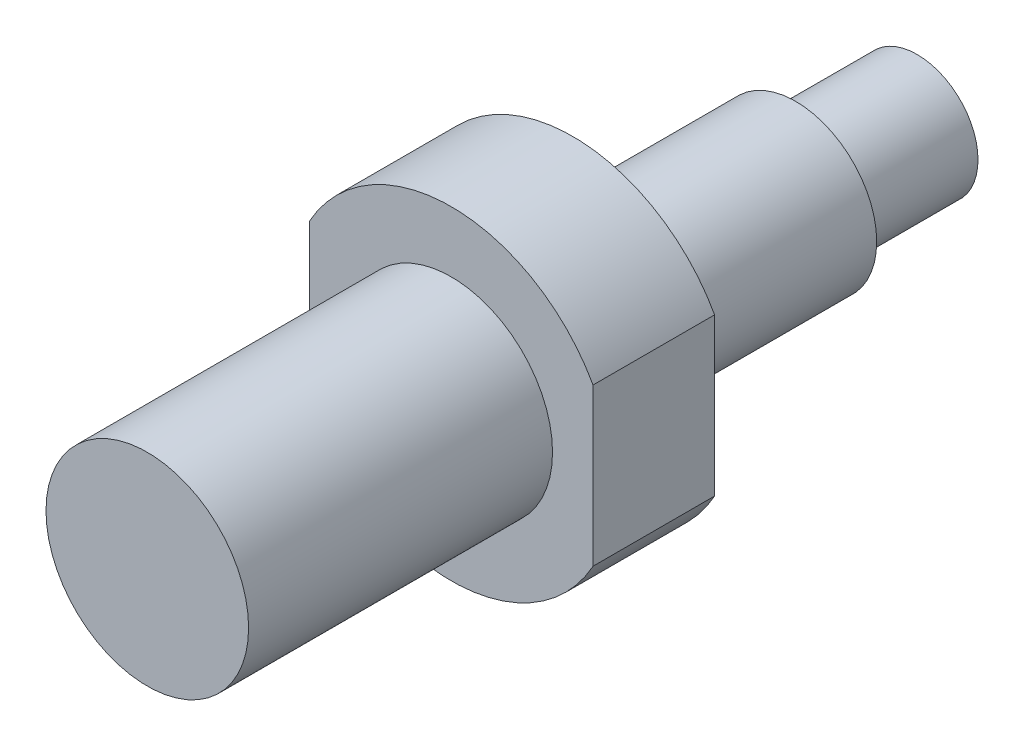
from build123d import *

# Parameters (mm, degrees)
SKETCH_3_W          = 8
SKETCH_3_H          = 16.823898374
CUT_EXTRUDE_1_DEPTH = 10
SKETCH_5_OUTSIDE_W  = 23.858
SKETCH_5_OUTSIDE_H  = 27.858
SKETCH_5_OUTSIDE_R  = 8
CUT_EXTRUDE_2_DEPTH = 10
SKETCH_6_R          = 3
EXTRUDE_1_DEPTH     = 6


with BuildPart() as part:
    # 草图2 → 旋转1 (revolve)
    with BuildSketch(Plane(origin=(0, 0, 0), x_dir=(0, 0, -1), z_dir=(1, 0, 0))):
        Polygon((0, 0), (0, 5), (15, 5), (15, 9), (21, 9), (21, 4), (32, 4), (32, 0), align=None)
    revolve(axis=Axis((0, 0, 0), (0, 0, -1)))

    # 草图3 → 切除-拉伸1 (cut)
    with BuildSketch(Plane.XY.offset(-15)):
        with Locations((-11, -0.026043186)):
            Rectangle(SKETCH_3_W, SKETCH_3_H)
        with Locations((11, -0.026043186)):
            Rectangle(SKETCH_3_W, SKETCH_3_H)
    extrude(amount=-CUT_EXTRUDE_1_DEPTH, mode=Mode.SUBTRACT)

    # 草图5 outside → 切除-拉伸2 (cut)
    with BuildSketch(Plane(origin=(0, 0, -21), x_dir=(-1, 0, 0), z_dir=(0, 0, -1))):
        Rectangle(SKETCH_5_OUTSIDE_W, SKETCH_5_OUTSIDE_H)
        Circle(SKETCH_5_OUTSIDE_R, mode=Mode.SUBTRACT)
    extrude(amount=-CUT_EXTRUDE_2_DEPTH, mode=Mode.SUBTRACT)

    # 草图6 → 凸台-拉伸1 (add)
    with BuildSketch(Plane(origin=(0, 0, -32), x_dir=(-1, 0, 0), z_dir=(0, 0, -1))):
        Circle(SKETCH_6_R)
    extrude(amount=EXTRUDE_1_DEPTH)


solid = part.part
